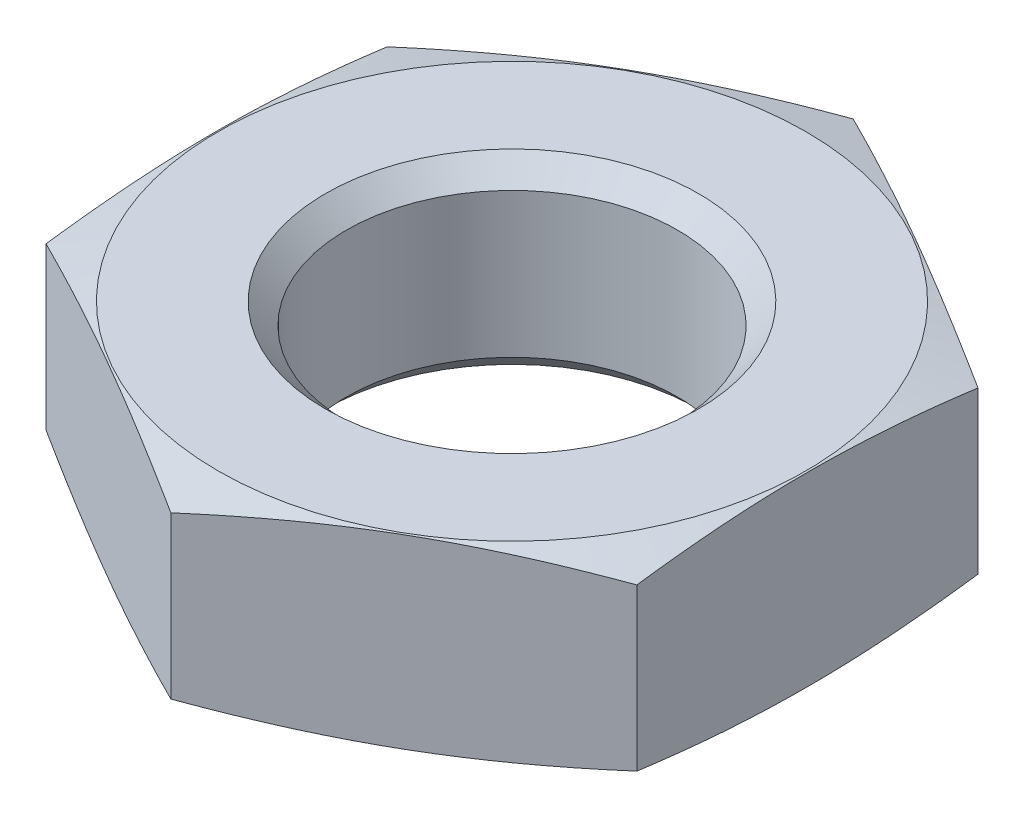
from build123d import *

# Parameters (mm, degrees)
CUT_EXTRUDE1_DEPTH      = 7
CUT_EXTRUDE1_DEPTH_BACK = 7
SKETCH2_W               = 76
SKETCH2_H               = 76


with BuildPart() as part:
    # Sketch1 → Revolve1 (revolve)
    with BuildSketch(Plane.XY):
        Polygon((0, 0), (9.45, 0), (20.646152423, -3), (9.45, -6), (0, -6), align=None)
    revolve(axis=Axis((0, -6, 0), (0, 1, 0)))

    # Sketch2 → Cut-Extrude1 (cut, two sides: drawn at the far end of the back side and taken through both)
    with BuildSketch(Plane(origin=(0, 0, 0), x_dir=(1, 0, 0), z_dir=(0, 1, 0)).offset(-CUT_EXTRUDE1_DEPTH_BACK)):
        Rectangle(SKETCH2_W, SKETCH2_H)
        Polygon((-9.5, -5.484827557), (0, -10.969655115), (9.5, -5.484827557), (9.5, 5.484827557), (0, 10.969655115), (-9.5, 5.484827557), align=None, mode=Mode.SUBTRACT)
    extrude(amount=CUT_EXTRUDE1_DEPTH + CUT_EXTRUDE1_DEPTH_BACK, mode=Mode.SUBTRACT)

    # Sketch3 → Cut-Revolve1 (revolve, cut)
    with BuildSketch(Plane.XY):
        Polygon((0, 0), (6, 0), (5.3235, -0.6765), (5.3235, -5.3235), (6, -6), (0, -6), align=None)
    revolve(axis=Axis((0, -6, 0), (0, 1, 0)), mode=Mode.SUBTRACT)


solid = part.part
